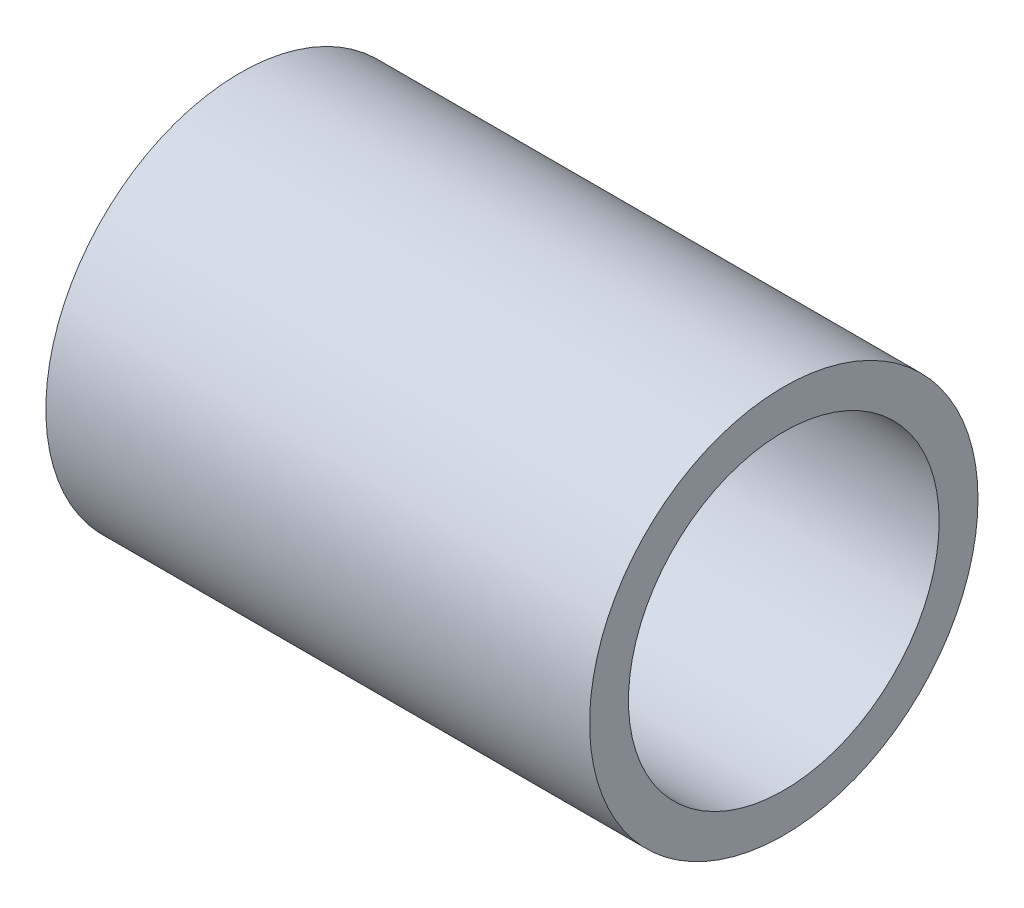
from build123d import *

# Parameters (mm, degrees)
SKETCH1_R           = 2.5
SKETCH1_R_2         = 2
BOSS_EXTRUDE1_DEPTH = 7


with BuildPart() as part:
    # Sketch1 → Boss-Extrude1 (new body)
    with BuildSketch(Plane(origin=(0, 0, 0), x_dir=(0, 0, -1), z_dir=(1, 0, 0))):
        Circle(SKETCH1_R)
        Circle(SKETCH1_R_2, mode=Mode.SUBTRACT)
    extrude(amount=BOSS_EXTRUDE1_DEPTH)


solid = part.part
